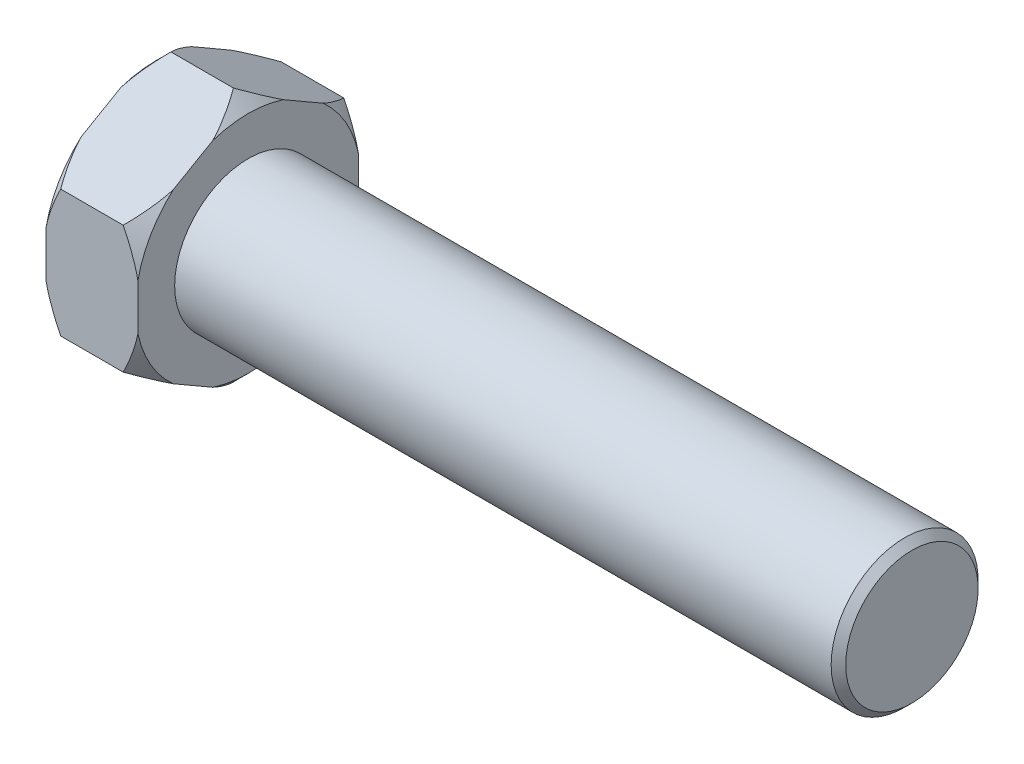
from build123d import *

# Parameters (mm, degrees)
ESBO_O2_R             = 28.575
CORTE_EXTRUS_O1_DEPTH = 11.9126


with BuildPart() as part:
    # Esboço1 → Revolução1 (revolve)
    with BuildSketch(Plane.XY):
        Polygon((-11.9126, 0), (-11.9126, 14.5923), (-9.4996, 17.0053), (-2.413, 17.0053), (0, 14.5923), (0, 9.525), (85.09, 9.525), (86.03615, 8.57885), (86.03615, 0), align=None)
    revolve(axis=Axis((86.03615, 0, 0), (-1, 0, 0)))

    # Esboço2 → Corte-extrusão1 (cut)
    with BuildSketch(Plane(origin=(0, 0, 0), x_dir=(0, 0, -1), z_dir=(1, 0, 0))):
        Circle(ESBO_O2_R)
        Polygon((-14.2875, -8.248891971), (0, -16.497783942), (14.2875, -8.248891971), (14.2875, 8.248891971), (0, 16.497783942), (-14.2875, 8.248891971), align=None, mode=Mode.SUBTRACT)
    extrude(amount=-CORTE_EXTRUS_O1_DEPTH, mode=Mode.SUBTRACT)


solid = part.part
